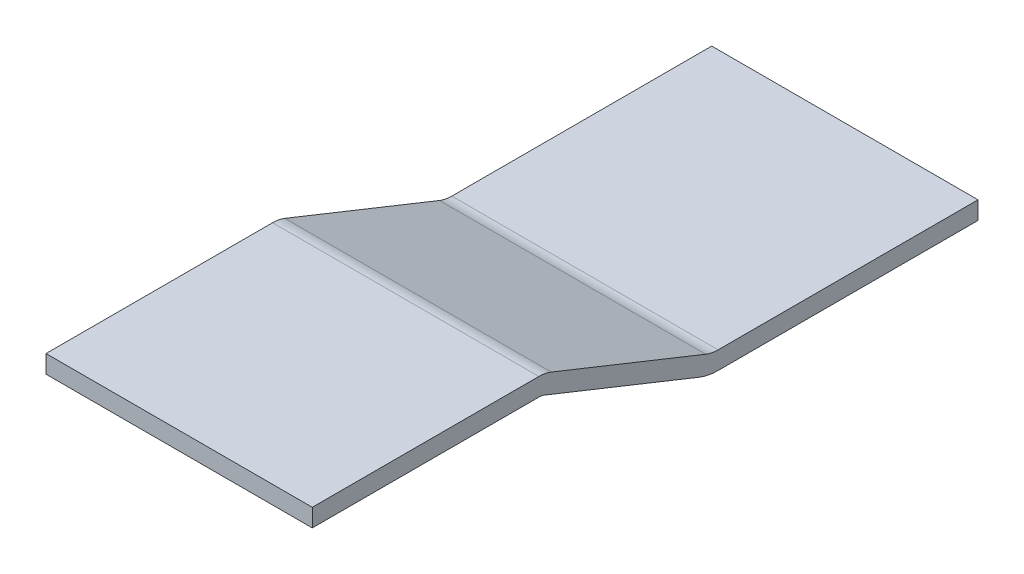
from build123d import *

# Parameters (mm, degrees)
BASE_THIN_DEPTH = 25.4


with BuildPart() as part:
    # Sketch1 → Base Thin (new body, symmetric)
    with BuildSketch(Plane(origin=(0, 0, 0), x_dir=(0, 0, -1), z_dir=(1, 0, 0))):
        with BuildLine():
            Line((-21.613550869, 0), (21.613550869, 0))
            ThreePointArc((21.613550869, 0), (22.814383628, -0.114576944), (23.971881664, -0.454173013))
            Line((23.971881664, -0.454173013), (53.451016599, -12.245826987))
            ThreePointArc((53.451016599, -12.245826987), (54.608514635, -12.585423056), (55.809347394, -12.7))
            Line((55.809347394, -12.7), (105.386449131, -12.7))
            Line((105.386449131, -12.7), (105.386449131, -16.1163))
            Line((105.386449131, -16.1163), (55.809347394, -16.1163))
            ThreePointArc((55.809347394, -16.1163), (53.96246661, -15.94008066), (52.182234632, -15.417781906))
            Line((52.182234632, -15.417781906), (22.703099696, -3.626127932))
            ThreePointArc((22.703099696, -3.626127932), (22.168335603, -3.469234548), (21.613550869, -3.4163))
            Line((21.613550869, -3.4163), (-21.613550869, -3.4163))
            Line((-21.613550869, -3.4163), (-21.613550869, 0))
        make_face()
    extrude(amount=BASE_THIN_DEPTH, both=True)


solid = part.part
